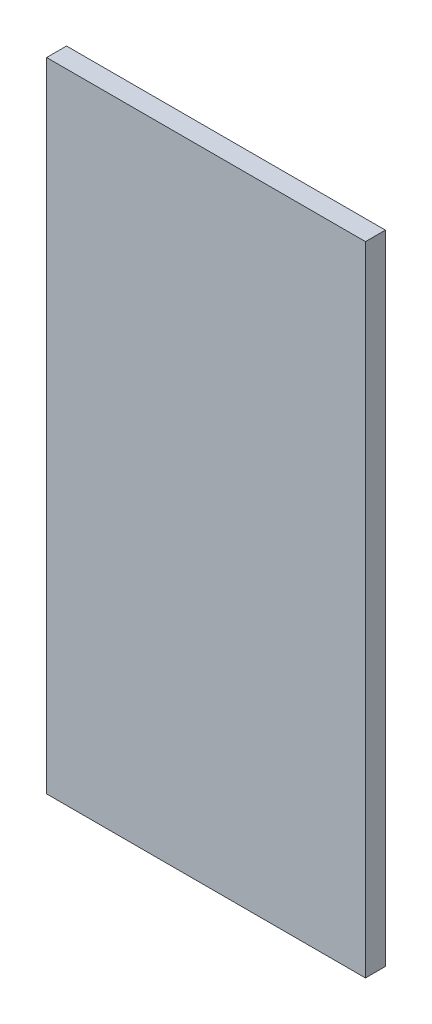
from build123d import *

# Parameters (mm, degrees)
SKETCH1_W           = 101.6
SKETCH1_H           = 203.2
BOSS_EXTRUDE1_DEPTH = 6.35


with BuildPart() as part:
    # Sketch1 → Boss-Extrude1 (new body)
    with BuildSketch(Plane.XY):
        Rectangle(SKETCH1_W, SKETCH1_H)
    extrude(amount=BOSS_EXTRUDE1_DEPTH)


solid = part.part
